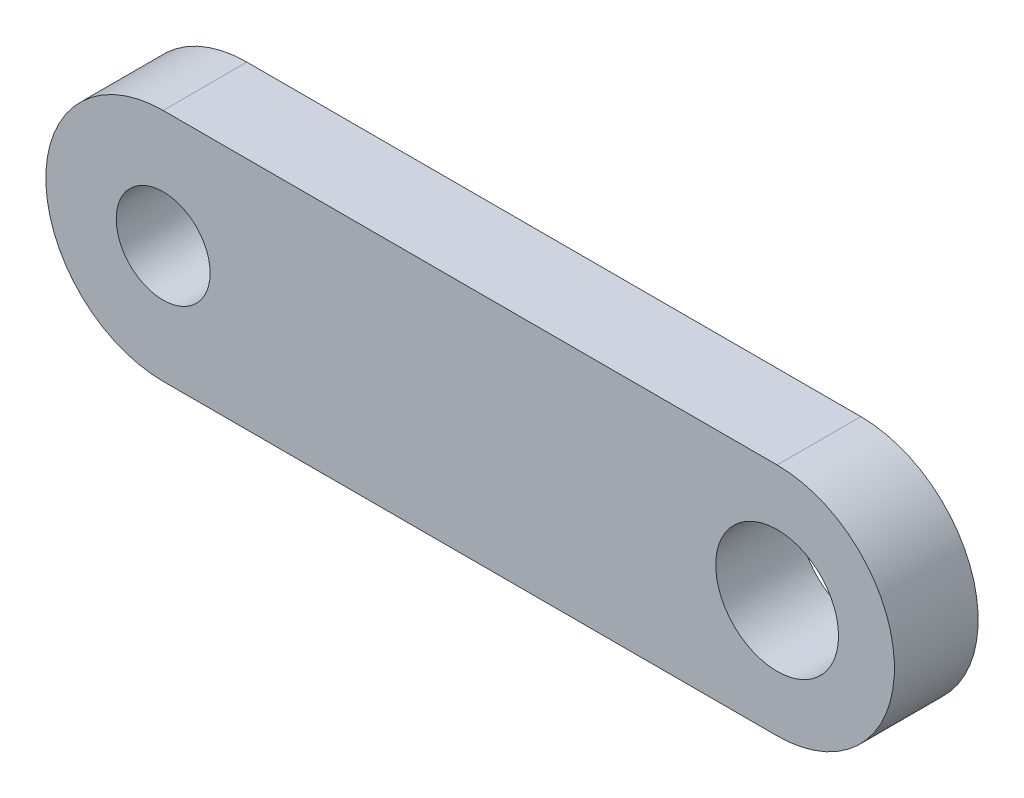
from build123d import *

# Parameters (mm, degrees)
MODEL_R             = 2.199999997
MODEL_R_2           = 1.682352939
BOSS_EXTRUDE1_DEPTH = 3


with BuildPart() as part:
    # Model → Boss-Extrude1 (new body)
    with BuildSketch(Plane.XY):
        with BuildLine():
            Line((64.051409634, 50.149226664), (78.999546271, 50.149226664))
            Line((78.999546271, 50.149226664), (80.881972122, 50.149226664))
            ThreePointArc((80.881972122, 50.149226664), (85.085686549, 54.352941092), (80.881972122, 58.55665552))
            Line((80.881972122, 58.55665552), (58.88197211, 58.55665552))
            ThreePointArc((58.88197211, 58.55665552), (54.678257705, 54.352941069), (58.881972156, 50.149226664))
            Line((58.881972156, 50.149226664), (64.051409634, 50.149226664))
        make_face()
        with Locations((80.881972122, 54.352233082)):
            Circle(MODEL_R, mode=Mode.SUBTRACT)
        with Locations((58.881972133, 54.352941092)):
            Circle(MODEL_R_2, mode=Mode.SUBTRACT)
    extrude(amount=BOSS_EXTRUDE1_DEPTH)


solid = part.part
